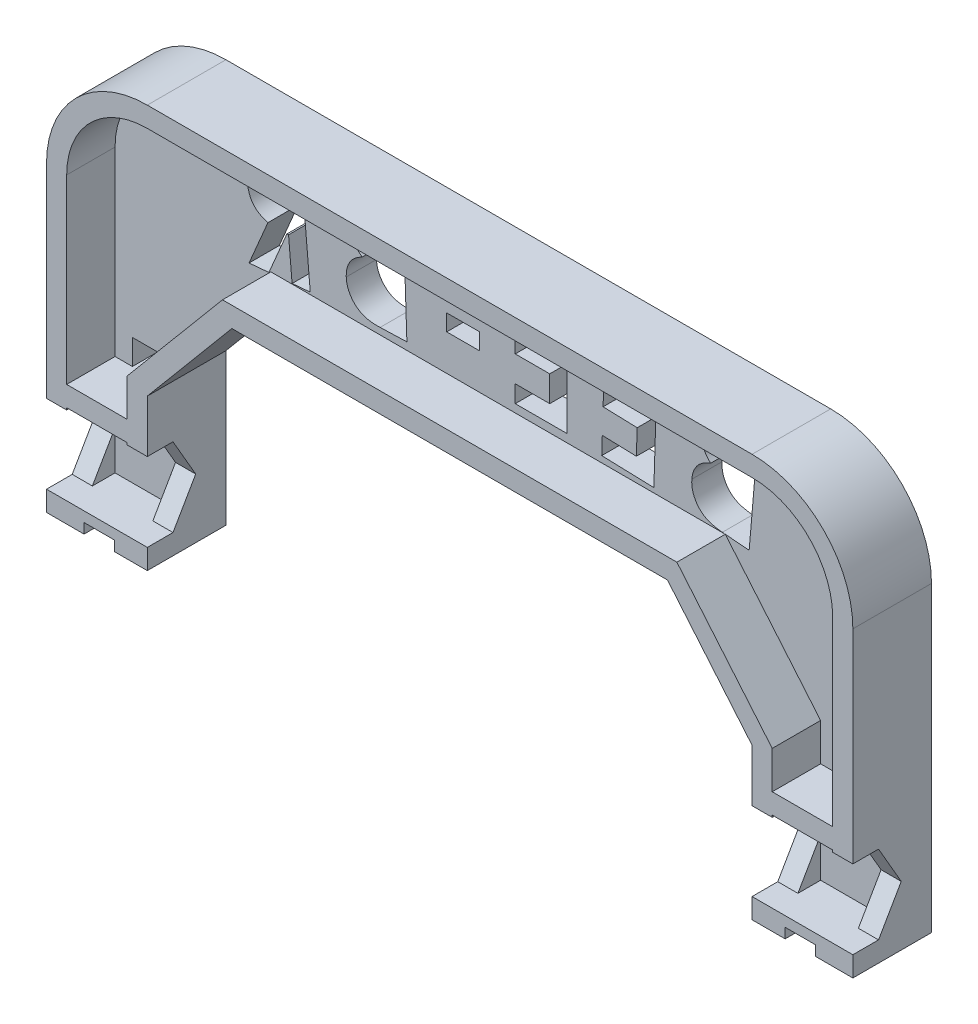
from build123d import *

# Parameters (mm, degrees)
RESSALTO_EXTRUS_O1_DEPTH      = 3
ESBO_O1_4_W                   = 2
ESBO_O1_4_H                   = 2
ESBO_O1_4_W_2                 = 6
ESBO_O1_4_H_2                 = 8
RESSALTO_EXTRUS_O2_DEPTH      = 7.8
RESSALTO_EXTRUS_O3_START      = 7.8
ESBO_O1_5_W                   = 2
ESBO_O1_5_H                   = 8
ESBO_O1_5_H_2                 = 2
ESBO_O1_5_W_2                 = 6
RESSALTO_EXTRUS_O3_DEPTH      = 6.5
RESSALTO_EXTRUS_O3_DEPTH_BACK = 1
CORTE_EXTRUS_O1_DEPTH         = 86.026407663
CORTE_EXTRUS_O2_DEPTH         = 90.8
CORTE_EXTRUS_O3_START         = -12
ESBO_O6_W                     = 80
ESBO_O6_H                     = 6.5
CORTE_EXTRUS_O3_DEPTH         = 12
ESBO_O8_W                     = 3
ESBO_O8_H                     = 2.5
ESBO_O8_H_2                   = 1
CORTE_EXTRUS_O4_DEPTH         = 19


with BuildPart() as part:
    # Esboço1 → Ressalto-extrusão1 (new body)
    with BuildSketch(Plane.XY):
        with BuildLine():
            Line((-30, -10), (-21.609003688, 0))
            Line((-21.609003688, 0), (21.609003688, 0))
            Line((21.609003688, 0), (30, -10))
            Line((30, -10), (30, -25))
            Line((30, -25), (40, -25))
            Line((40, -25), (40, 5))
            ThreePointArc((40, 5), (37.071067812, 12.071067812), (30, 15))
            Line((30, 15), (-30, 15))
            ThreePointArc((-30, 15), (-37.071067812, 12.071067812), (-40, 5))
            Line((-40, 5), (-40, -25))
            Line((-40, -25), (-30, -25))
            Line((-30, -25), (-30, -10))
        make_face()
    extrude(amount=RESSALTO_EXTRUS_O1_DEPTH)

    # Esboço1<4> → Ressalto-extrusão2 (add)
    with BuildSketch(Plane.XY):
        Polygon((-32, -25), (-32, -23), (-38, -23), (-40, -23), (-40, -25), align=None)
        with Locations((-31, -24)):
            Rectangle(ESBO_O1_4_W, ESBO_O1_4_H)
        with Locations((-35, -14)):
            Rectangle(ESBO_O1_4_W_2, ESBO_O1_4_H)
        with Locations((-31, -14)):
            Rectangle(ESBO_O1_4_W, ESBO_O1_4_H)
        with Locations((-39, -14)):
            Rectangle(ESBO_O1_4_W, ESBO_O1_4_H)
        Polygon((-32, -13), (-30, -13), (-30, -10), (-21.609003688, 0), (21.609003688, 0), (30, -10), (30, -13), (32, -13), (32, -9.272059531), (22.541619005, 2), (-22.541619005, 2), (-32, -9.272059531), align=None)
        with BuildLine():
            Line((-40, -13), (-38, -13))
            Line((-38, -13), (-38, 5))
            ThreePointArc((-38, 5), (-35.656854249, 10.656854249), (-30, 13))
            Line((-30, 13), (30, 13))
            ThreePointArc((30, 13), (35.656854249, 10.656854249), (38, 5))
            Line((38, 5), (38, -13))
            Line((38, -13), (40, -13))
            Line((40, -13), (40, 5))
            ThreePointArc((40, 5), (37.071067812, 12.071067812), (30, 15))
            Line((30, 15), (-30, 15))
            ThreePointArc((-30, 15), (-37.071067812, 12.071067812), (-40, 5))
            Line((-40, 5), (-40, -13))
        make_face()
        with Locations((39, -14)):
            Rectangle(ESBO_O1_4_W, ESBO_O1_4_H)
        with Locations((31, -14)):
            Rectangle(ESBO_O1_4_W, ESBO_O1_4_H)
        with Locations((31, -24)):
            Rectangle(ESBO_O1_4_W, ESBO_O1_4_H)
        Polygon((38, -23), (32, -23), (32, -25), (40, -25), (40, -23), align=None)
        with Locations((35, -14)):
            Rectangle(ESBO_O1_4_W_2, ESBO_O1_4_H)
        with Locations((-31, -19)):
            Rectangle(ESBO_O1_4_W, ESBO_O1_4_H_2)
        with Locations((-39, -19)):
            Rectangle(ESBO_O1_4_W, ESBO_O1_4_H_2)
        with Locations((39, -19)):
            Rectangle(ESBO_O1_4_W, ESBO_O1_4_H_2)
        with Locations((31, -19)):
            Rectangle(ESBO_O1_4_W, ESBO_O1_4_H_2)
    extrude(amount=RESSALTO_EXTRUS_O2_DEPTH)

    # Esboço1<5> → Ressalto-extrusão3 (add, two sides)
    with BuildSketch(Plane.XY.offset(RESSALTO_EXTRUS_O3_START)) as ressalto_extrus_o3_sk:
        with Locations((-39, -19)):
            Rectangle(ESBO_O1_5_W, ESBO_O1_5_H)
        Polygon((-32, -25), (-32, -23), (-38, -23), (-40, -23), (-40, -25), align=None)
        with Locations((-31, -24)):
            Rectangle(ESBO_O1_5_W, ESBO_O1_5_H_2)
        with Locations((-31, -14)):
            Rectangle(ESBO_O1_5_W, ESBO_O1_5_H_2)
        with Locations((-35, -14)):
            Rectangle(ESBO_O1_5_W_2, ESBO_O1_5_H_2)
        with Locations((-39, -14)):
            Rectangle(ESBO_O1_5_W, ESBO_O1_5_H_2)
        with Locations((-31, -19)):
            Rectangle(ESBO_O1_5_W, ESBO_O1_5_H)
        Polygon((38, -23), (32, -23), (32, -25), (40, -25), (40, -23), align=None)
        with Locations((31, -24)):
            Rectangle(ESBO_O1_5_W, ESBO_O1_5_H_2)
        with Locations((31, -19)):
            Rectangle(ESBO_O1_5_W, ESBO_O1_5_H)
        with Locations((31, -14)):
            Rectangle(ESBO_O1_5_W, ESBO_O1_5_H_2)
        with Locations((39, -19)):
            Rectangle(ESBO_O1_5_W, ESBO_O1_5_H)
        with Locations((39, -14)):
            Rectangle(ESBO_O1_5_W, ESBO_O1_5_H_2)
        with Locations((35, -14)):
            Rectangle(ESBO_O1_5_W_2, ESBO_O1_5_H_2)
    extrude(amount=RESSALTO_EXTRUS_O3_DEPTH)
    extrude(ressalto_extrus_o3_sk.sketch, amount=-RESSALTO_EXTRUS_O3_DEPTH_BACK)

    # Esboço2 → Corte-extrusão1 (cut, through all)
    with BuildSketch(Plane.ZY.offset(40)):
        Polygon((5.25166605, -23), (9.75499815, -23), (12.006664199, -19.1), (9.75499815, -15.2), (5.25166605, -15.2), (3, -19.1), align=None)
    extrude(amount=-CORTE_EXTRUS_O1_DEPTH, mode=Mode.SUBTRACT)

    # Esboço3 → Corte-extrusão2 (cut)
    with BuildSketch(Plane(origin=(0, 0, 0), x_dir=(-1, 0, 0), z_dir=(0, 0, -1))):
        with BuildLine():
            Line((-24.910939522, 1.799479276), (-25.721861998, 11.272961848))
            Line((-25.721861998, 11.272961848), (-24.233580748, 11.398893338))
            add(Edge.make_bspline(
                [(-24.233580748, 11.398893338), (-24.129306745, 11.407586683), (-23.927889288, 11.424378897), (-23.636514212, 11.441755378), (-23.366119032, 11.450688984), (-23.117357078, 11.456285064), (-22.889523075, 11.449775412), (-22.683425617, 11.438280168), (-22.49763069, 11.423568073), (-22.382019918, 11.402918558), (-22.327435916, 11.39316918)],
                knots=[0, 0, 0, 0, 1.313966022, 2.538079354, 3.664944948, 4.71135529, 5.662102467, 6.526021516, 7.304081761, 8, 8, 8, 8], degree=3))
            add(Edge.make_bspline(
                [(-22.327435916, 11.39316918), (-22.256593664, 11.379606887), (-22.116905433, 11.352864474), (-21.914216589, 11.294833367), (-21.720702926, 11.224614715), (-21.537670734, 11.139742514), (-21.362339691, 11.045688204), (-21.200529267, 10.932607536), (-21.044931075, 10.811853962), (-20.902174658, 10.675500117), (-20.771008955, 10.52969755), (-20.654089611, 10.374606719), (-20.552536162, 10.21180895), (-20.465900549, 10.040855527), (-20.395091314, 9.860665842), (-20.34055482, 9.672111647), (-20.299139833, 9.475705497), (-20.285251037, 9.341553089), (-20.278187118, 9.273322425)],
                knots=[0, 0, 0, 0, 1.085588587, 2.140586228, 3.170688593, 4.182012061, 5.176371104, 6.161836047, 7.150460134, 8.139501588, 9.129655157, 10.100729556, 11.060021403, 12.015097404, 12.982528871, 13.970456957, 14.967763074, 16, 16, 16, 16], degree=3))
            add(Edge.make_bspline(
                [(-20.278187118, 9.273322425), (-20.272812811, 9.184926321), (-20.262243451, 9.011082451), (-20.284254904, 8.753922925), (-20.335995005, 8.506479089), (-20.419238502, 8.268263892), (-20.532889076, 8.034838038), (-20.686063901, 7.810369103), (-20.872901117, 7.587889131), (-21.018854751, 7.451522345), (-21.094833753, 7.380533963)],
                knots=[0, 0, 0, 0, 0.988972813, 1.944959711, 2.87510724, 3.808293588, 4.759083714, 5.768773294, 6.838491573, 8, 8, 8, 8], degree=3))
            add(Edge.make_bspline(
                [(-21.094833753, 7.380533963), (-21.021908785, 7.352906395), (-20.878709221, 7.298655348), (-20.675800835, 7.20224047), (-20.48471665, 7.101842949), (-20.309982528, 6.99028723), (-20.146823666, 6.874766863), (-19.998504415, 6.749899451), (-19.865661335, 6.616087659), (-19.744226803, 6.47649637), (-19.636605473, 6.328222872), (-19.541507261, 6.171583391), (-19.457455709, 6.007906157), (-19.3858424, 5.835684545), (-19.327736255, 5.655453876), (-19.279928619, 5.46749254), (-19.242455728, 5.271999148), (-19.22958728, 5.138081193), (-19.223033873, 5.06988192)],
                knots=[0, 0, 0, 0, 1.181829229, 2.320706277, 3.403542679, 4.452266086, 5.461131016, 6.432812402, 7.387405613, 8.317228163, 9.235326515, 10.161441584, 11.092962624, 12.022385079, 12.985994604, 13.96125793, 14.961746936, 16, 16, 16, 16], degree=3))
            add(Edge.make_bspline(
                [(-19.223033873, 5.06988192), (-19.2165564, 4.938770926), (-19.203777409, 4.680110426), (-19.253126284, 4.296623788), (-19.349384328, 3.925687081), (-19.50368905, 3.575612965), (-19.696036732, 3.250762823), (-19.925938036, 2.960709753), (-20.188646227, 2.708114681), (-20.437995214, 2.53202002), (-20.655623267, 2.410108848), (-20.836195565, 2.327732639), (-21.033230053, 2.256447188), (-21.246166827, 2.190501189), (-21.475860065, 2.136425446), (-21.721760262, 2.090990357), (-21.98322567, 2.052047931), (-22.163878063, 2.035204726), (-22.256837959, 2.026537569)],
                knots=[0, 0, 0, 0, 1.29558415, 2.555975173, 3.805148212, 5.072546849, 6.324565388, 7.528543806, 8.720458455, 9.915603118, 10.534905023, 11.184890737, 11.875232468, 12.605216168, 13.387618399, 14.206515762, 15.07711098, 16, 16, 16, 16], degree=3))
            Line((-22.256837959, 2.026537569), (-24.910939522, 1.799479276))
        make_face()
        with BuildLine():
            Line((-23.77183195, 9.708358483), (-23.602015243, 7.710627112))
            Line((-23.602015243, 7.710627112), (-23.208956349, 7.743064012))
            add(Edge.make_bspline(
                [(-23.208956349, 7.743064012), (-23.106739431, 7.754930871), (-22.9144479, 7.77725493), (-22.649227364, 7.850315967), (-22.429180251, 7.957141317), (-22.252536531, 8.094651338), (-22.125831592, 8.262990624), (-22.036038848, 8.4505902), (-21.993909403, 8.662272792), (-21.999937434, 8.80827937), (-22.003066926, 8.884079637)],
                knots=[0, 0, 0, 0, 1.309259117, 2.462991907, 3.484474685, 4.40662182, 5.284673551, 6.143423425, 7.036146178, 8, 8, 8, 8], degree=3))
            add(Edge.make_bspline(
                [(-22.003066926, 8.884079637), (-22.01212709, 8.954724988), (-22.029567142, 9.090711336), (-22.104352351, 9.278770734), (-22.215618085, 9.439828669), (-22.364979607, 9.571664428), (-22.548814746, 9.674928381), (-22.772119257, 9.735640607), (-23.029045347, 9.764354457), (-23.211476833, 9.752698049), (-23.308175099, 9.74651954)],
                knots=[0, 0, 0, 0, 0.960098706, 1.848109079, 2.707028349, 3.584142476, 4.519774804, 5.532262408, 6.691969519, 8, 8, 8, 8], degree=3))
            Line((-23.308175099, 9.74651954), (-23.77183195, 9.708358483))
        make_face(mode=Mode.SUBTRACT)
        with BuildLine():
            Line((-23.462727383, 6.102138531), (-23.254749618, 3.673187209))
            Line((-23.254749618, 3.673187209), (-22.804449137, 3.711348266))
            add(Edge.make_bspline(
                [(-22.804449137, 3.711348266), (-22.714691252, 3.719501259), (-22.543051933, 3.735091803), (-22.297871283, 3.769308394), (-22.076494908, 3.811552918), (-21.877722721, 3.857566086), (-21.703338355, 3.913500415), (-21.551602907, 3.972992402), (-21.42369243, 4.041714531), (-21.318877192, 4.118903482), (-21.233058423, 4.203638893), (-21.159747546, 4.293260641), (-21.099923793, 4.391482552), (-21.054759937, 4.497247706), (-21.019633271, 4.608287537), (-20.998745443, 4.726863702), (-20.990978732, 4.8523745), (-20.996573039, 4.938242481), (-20.999431108, 4.982111487)],
                knots=[0, 0, 0, 0, 1.719239493, 3.287611936, 4.720190196, 6.018023643, 7.176886393, 8.211086977, 9.123282731, 9.938670018, 10.685153, 11.41850386, 12.142662851, 12.870775423, 13.607631086, 14.359713874, 15.16199587, 16, 16, 16, 16], degree=3))
            add(Edge.make_bspline(
                [(-20.999431108, 4.982111487), (-21.004442252, 5.031957285), (-21.014182719, 5.128845623), (-21.051022788, 5.267498336), (-21.095140571, 5.398489283), (-21.157148766, 5.519294292), (-21.2327144, 5.630761305), (-21.319782864, 5.735265672), (-21.425075794, 5.825603224), (-21.539375723, 5.911602032), (-21.671611588, 5.98433719), (-21.820892623, 6.046366943), (-21.989770057, 6.089007611), (-22.174570729, 6.127883069), (-22.377975566, 6.145932384), (-22.598888308, 6.156197182), (-22.837844443, 6.151981213), (-23.002940146, 6.139272671), (-23.088749017, 6.132667377)],
                knots=[0, 0, 0, 0, 0.887704196, 1.72548518, 2.539505422, 3.337158996, 4.126138673, 4.926901397, 5.74248556, 6.58239328, 7.461732246, 8.413447965, 9.443111175, 10.547821151, 11.762049063, 13.061444902, 14.472679217, 16, 16, 16, 16], degree=3))
            Line((-23.088749017, 6.132667377), (-23.462727383, 6.102138531))
        make_face(mode=Mode.SUBTRACT)
        Polygon((-15.756681011, 11.935736384), (-10.58394964, 12.099828932), (-10.528616107, 10.334880014), (-13.909685818, 10.228029053), (-13.854352285, 8.514597562), (-10.473282573, 8.621448524), (-10.419857092, 6.888936505), (-13.800926804, 6.782085543), (-13.720788583, 4.290168476), (-10.339718871, 4.397019437), (-10.284385337, 2.62634636), (-15.457116708, 2.462253812), align=None)
        Polygon((-6.832522431, 12.324855334), (-1.703676277, 12.324855334), (-1.703676277, 10.61523995), (-5.122907046, 10.61523995), (-5.122907046, 8.78350918), (-1.703676277, 8.78350918), (-1.703676277, 7.073893796), (-5.122907046, 7.073893796), (-5.122907046, 4.509470719), (-1.703676277, 4.509470719), (-1.703676277, 2.799855334), (-6.832522431, 2.799855334), align=None)
        Polygon((1.829885506, 7.206468083), (5.102196203, 7.200743924), (5.098380097, 5.565542602), (1.8260694, 5.571266761), align=None)
        with BuildLine():
            Line((9.047182886, 2.736627532), (9.362011612, 12.210110104))
            Line((9.362011612, 12.210110104), (10.850292862, 12.160500729))
            add(Edge.make_bspline(
                [(10.850292862, 12.160500729), (10.954617699, 12.156424264), (11.155715083, 12.148566438), (11.446407616, 12.131137245), (11.714989946, 12.110979273), (11.961978819, 12.084770423), (12.186897757, 12.051297256), (12.390988765, 12.01846698), (12.572917568, 11.979523243), (12.684754634, 11.945587838), (12.737357164, 11.92962633)],
                knots=[0, 0, 0, 0, 1.314487014, 2.533815602, 3.666356561, 4.70543794, 5.660122908, 6.529004863, 7.308117873, 8, 8, 8, 8], degree=3))
            add(Edge.make_bspline(
                [(12.737357164, 11.92962633), (12.805812519, 11.907831137), (12.941388921, 11.864665575), (13.134532865, 11.781820277), (13.318286416, 11.690193294), (13.489678395, 11.585069637), (13.650589339, 11.468493899), (13.799954, 11.34023818), (13.937756757, 11.200445091), (14.063679706, 11.049961375), (14.175518286, 10.89011754), (14.274308469, 10.723787821), (14.353898504, 10.549298292), (14.419007429, 10.369369583), (14.469633958, 10.183217996), (14.500935549, 9.990095509), (14.519017758, 9.791054996), (14.518056887, 9.656536843), (14.517570506, 9.58844544)],
                knots=[0, 0, 0, 0, 1.084518904, 2.147898747, 3.17039799, 4.183649399, 5.180927192, 6.168721053, 7.153708144, 8.142622483, 9.128733241, 10.09751886, 11.060332373, 12.020602502, 12.985331112, 13.969240152, 14.97205483, 16, 16, 16, 16], degree=3))
            add(Edge.make_bspline(
                [(14.517570506, 9.58844544), (14.512115291, 9.500412161), (14.501392606, 9.327375306), (14.448023476, 9.075055604), (14.368624561, 8.835610516), (14.258104474, 8.609225337), (14.116342253, 8.394531695), (13.94049855, 8.188609431), (13.727465561, 7.992133517), (13.566667849, 7.873485071), (13.483405842, 7.812048205)],
                knots=[0, 0, 0, 0, 0.987986378, 1.941970776, 2.882502406, 3.810757125, 4.758320916, 5.760163861, 6.840199605, 8, 8, 8, 8], degree=3))
            add(Edge.make_bspline(
                [(13.483405842, 7.812048205), (13.552432386, 7.775137032), (13.687160291, 7.703092791), (13.879418749, 7.586956559), (14.054215993, 7.462426607), (14.216453734, 7.334312459), (14.363121119, 7.199059692), (14.495376888, 7.057643259), (14.612407375, 6.910390454), (14.713904845, 6.756803323), (14.802127587, 6.597116902), (14.87879031, 6.431558288), (14.941036269, 6.258843269), (14.994322887, 6.080993584), (15.028787885, 5.895331821), (15.054572103, 5.70371369), (15.065548248, 5.50533669), (15.064038573, 5.371017402), (15.063273631, 5.302958661)],
                knots=[0, 0, 0, 0, 1.19002917, 2.322731646, 3.412004466, 4.451014966, 5.463821004, 6.442204954, 7.392124064, 8.320083953, 9.237708086, 10.16365045, 11.090602125, 12.027038084, 12.982845179, 13.957974222, 14.965318353, 16, 16, 16, 16], degree=3))
            add(Edge.make_bspline(
                [(15.063273631, 5.302958661), (15.054388785, 5.1726828), (15.03685168, 4.915541443), (14.943914679, 4.5415548), (14.802007182, 4.186663194), (14.609139979, 3.857557516), (14.379614189, 3.558671073), (14.118218178, 3.298106879), (13.827264046, 3.080336393), (13.561341181, 2.934490559), (13.331796006, 2.839103853), (13.142803872, 2.781767484), (12.939885406, 2.731183261), (12.721000131, 2.694090774), (12.48738438, 2.665328812), (12.238346166, 2.648545964), (11.974771493, 2.643185307), (11.794138596, 2.646931416), (11.701284448, 2.648857099)],
                knots=[0, 0, 0, 0, 1.293209402, 2.552565116, 3.803787532, 5.073091564, 6.323645754, 7.532624737, 8.722505474, 9.916843678, 10.530766191, 11.185263696, 11.873842807, 12.604054984, 13.385812867, 14.207947857, 15.078797514, 16, 16, 16, 16], degree=3))
            Line((11.701284448, 2.648857099), (9.047182886, 2.736627532))
        make_face()
        with BuildLine():
            Line((11.107880001, 10.431804815), (11.04109815, 8.434073445))
            Line((11.04109815, 8.434073445), (11.434157044, 8.420717075))
            add(Edge.make_bspline(
                [(11.434157044, 8.420717075), (11.536663867, 8.420603604), (11.729373073, 8.420390282), (12.000185411, 8.45992278), (12.230513128, 8.540105199), (12.421230156, 8.655658098), (12.568967197, 8.805722715), (12.676580129, 8.982745991), (12.745754379, 9.186118413), (12.756549488, 9.331563622), (12.762161852, 9.407180416)],
                knots=[0, 0, 0, 0, 1.308947509, 2.46077507, 3.478771254, 4.405781035, 5.285103298, 6.142362923, 7.034216663, 8, 8, 8, 8], degree=3))
            add(Edge.make_bspline(
                [(12.762161852, 9.407180416), (12.761337853, 9.478072106), (12.759755121, 9.614240359), (12.70884135, 9.809261656), (12.616472726, 9.98099358), (12.486189332, 10.131437373), (12.313958919, 10.252549896), (12.10182118, 10.343074823), (11.849526161, 10.398134283), (11.667853327, 10.410163127), (11.571536852, 10.416540392)],
                knots=[0, 0, 0, 0, 0.958911669, 1.841870698, 2.70246622, 3.582935599, 4.516525514, 5.53255725, 6.691849617, 8, 8, 8, 8], degree=3))
            Line((11.571536852, 10.416540392), (11.107880001, 10.431804815))
        make_face(mode=Mode.SUBTRACT)
        with BuildLine():
            Line((10.987672669, 6.825584863), (10.907534448, 4.396633541))
            Line((10.907534448, 4.396633541), (11.357834929, 4.381369118))
            add(Edge.make_bspline(
                [(11.357834929, 4.381369118), (11.44750682, 4.379628128), (11.619220558, 4.376294285), (11.86624788, 4.378918583), (12.090484961, 4.393778634), (12.29220197, 4.419158544), (12.472079165, 4.44945066), (12.629202013, 4.493408312), (12.764252295, 4.545880154), (12.877821928, 4.609880599), (12.972534572, 4.684323071), (13.055103822, 4.764853914), (13.127912782, 4.853158567), (13.183459828, 4.953040008), (13.230791359, 5.059382038), (13.264204141, 5.174302816), (13.288398443, 5.29754412), (13.29243119, 5.382974014), (13.294508607, 5.426982099)],
                knots=[0, 0, 0, 0, 1.715703643, 3.285420693, 4.724409075, 6.011686423, 7.173926675, 8.210114093, 9.127403779, 9.939309915, 10.693755025, 11.425085138, 12.143343792, 12.873762464, 13.60387707, 14.366033249, 15.158283534, 16, 16, 16, 16], degree=3))
            add(Edge.make_bspline(
                [(13.294508607, 5.426982099), (13.295047998, 5.4766461), (13.296102847, 5.573770524), (13.277820396, 5.715689158), (13.24766946, 5.850898215), (13.202358213, 5.978868453), (13.140120905, 6.098062481), (13.064710385, 6.210106062), (12.975388387, 6.315518636), (12.868547071, 6.410811985), (12.74774755, 6.501112921), (12.605028352, 6.575341425), (12.445478301, 6.643661485), (12.265203814, 6.697172712), (12.066561646, 6.74353968), (11.848275529, 6.776387493), (11.611502066, 6.802104535), (11.446948361, 6.808772248), (11.361651035, 6.812228493)],
                knots=[0, 0, 0, 0, 0.883019077, 1.726858855, 2.539682352, 3.345301018, 4.135097291, 4.926271423, 5.745220041, 6.586626684, 7.469645761, 8.421857886, 9.441522381, 10.555073518, 11.763276166, 13.069723502, 14.481074902, 16, 16, 16, 16], degree=3))
            Line((11.361651035, 6.812228493), (10.987672669, 6.825584863))
        make_face(mode=Mode.SUBTRACT)
        with BuildLine():
            Line((19.461989353, 11.685693059), (21.375766397, 11.517784406))
            add(Edge.make_bspline(
                [(21.375766397, 11.517784406), (21.501767184, 11.505709202), (21.744545188, 11.48244273), (22.093843999, 11.438490066), (22.414023077, 11.38953689), (22.705715408, 11.334495926), (22.968536679, 11.272990007), (23.201163323, 11.201831836), (23.406184383, 11.128599072), (23.584391582, 11.045063928), (23.744484859, 10.953635256), (23.891294989, 10.852006444), (24.030425405, 10.740587669), (24.159405903, 10.617356744), (24.277761125, 10.482105066), (24.390165475, 10.338884293), (24.48999886, 10.182158981), (24.58180952, 10.016761072), (24.661714289, 9.842502304), (24.73115437, 9.662005721), (24.783947812, 9.474005489), (24.824631824, 9.280246022), (24.850187924, 9.079866499), (24.866597889, 8.873545), (24.86612308, 8.660525163), (24.85565978, 8.517006792), (24.850330699, 8.443911208)],
                knots=[0, 0, 0, 0, 1.706242283, 3.287583397, 4.745122099, 6.071840018, 7.288377294, 8.381422042, 9.349801241, 10.220491494, 11.030836279, 11.832287683, 12.624977777, 13.43150359, 14.233230108, 15.046110905, 15.883227537, 16.735141512, 17.59444415, 18.465472044, 19.339322555, 20.223791933, 21.132003346, 22.060506007, 23.012193042, 24, 24, 24, 24], degree=3))
            add(Edge.make_bspline(
                [(24.850330699, 8.443911208), (24.842481921, 8.367448333), (24.827102426, 8.217621144), (24.786587291, 7.999566654), (24.733052329, 7.792356221), (24.666798522, 7.595584178), (24.586026586, 7.410401259), (24.494587235, 7.234564511), (24.387228995, 7.071357911), (24.268845979, 6.917412374), (24.135871219, 6.775053948), (23.989112069, 6.644238027), (23.830011984, 6.52301575), (23.65666455, 6.413883545), (23.470298081, 6.315354116), (23.270354423, 6.226682441), (23.05685027, 6.151151627), (22.908809384, 6.108935937), (22.8335188, 6.087465896)],
                knots=[0, 0, 0, 0, 1.103647808, 2.162571673, 3.181780949, 4.175536025, 5.141138738, 6.08098974, 7.018484832, 7.943073067, 8.867345349, 9.811846367, 10.763740163, 11.736918372, 12.750380027, 13.789214674, 14.87563955, 16, 16, 16, 16], degree=3))
            Line((22.8335188, 6.087465896), (24.707226733, 1.679863732))
            Line((24.707226733, 1.679863732), (22.736208103, 1.853496545))
            Line((22.736208103, 1.853496545), (20.955994762, 6.051212891))
            Line((20.955994762, 6.051212891), (20.788086108, 6.066477314))
            Line((20.788086108, 6.066477314), (20.437004377, 2.053842098))
            Line((20.437004377, 2.053842098), (18.633894401, 2.212210487))
            Line((18.633894401, 2.212210487), (19.461989353, 11.685693059))
        make_face()
        with BuildLine():
            Line((20.940730339, 7.823794021), (21.507422046, 7.774184646))
            add(Edge.make_bspline(
                [(21.507422046, 7.774184646), (21.576707583, 7.768479905), (21.709415838, 7.757553148), (21.901100393, 7.751592664), (22.076205889, 7.755456212), (22.235486918, 7.766414791), (22.378929021, 7.78529265), (22.507008086, 7.810843988), (22.618966193, 7.846413258), (22.743386051, 7.90766501), (22.878033175, 8.00820513), (22.996590727, 8.175888507), (23.07556977, 8.382652493), (23.095680455, 8.534774801), (23.106370363, 8.615635968)],
                knots=[0, 0, 0, 0, 1.202426501, 2.303105821, 3.315514564, 4.231050406, 5.063490919, 5.816534758, 6.48800783, 7.08828922, 8.210531185, 9.352658199, 10.592795835, 12, 12, 12, 12], degree=3))
            add(Edge.make_bspline(
                [(23.106370363, 8.615635968), (23.109451398, 8.665938222), (23.115443764, 8.763772095), (23.094021973, 8.90699539), (23.057140354, 9.043062021), (22.994725788, 9.16828291), (22.917588593, 9.282494137), (22.823576951, 9.382416284), (22.71400471, 9.466547214), (22.582201116, 9.539343125), (22.413992003, 9.599634329), (22.195033636, 9.645699323), (21.92072743, 9.690019557), (21.717483398, 9.708442997), (21.606640796, 9.718490535)],
                knots=[0, 0, 0, 0, 0.850414144, 1.653987699, 2.43742129, 3.226745441, 4.008773503, 4.762447895, 5.537335357, 6.336935986, 7.300476977, 8.548276045, 10.117543424, 12, 12, 12, 12], degree=3))
            Line((21.606640796, 9.718490535), (21.110547046, 9.762375752))
            Line((21.110547046, 9.762375752), (20.940730339, 7.823794021))
        make_face(mode=Mode.SUBTRACT)
    extrude(amount=-CORTE_EXTRUS_O2_DEPTH, mode=Mode.SUBTRACT)


with BuildPart() as corte_extrus_o2_piece_1:
    # of the separate pieces the step leaves, piece 1, a body of its own (corte_extrus_o2_pieces)
    add(part.part.solids().sort_by_distance((-30, 15, 7.8))[0])

    # Esboço6 → Corte-extrusão3 (cut)
    with BuildSketch(Plane.XZ.offset(25).offset(CORTE_EXTRUS_O3_START)):
        with Locations((0, 11.05)):
            Rectangle(ESBO_O6_W, ESBO_O6_H)
    extrude(amount=CORTE_EXTRUS_O3_DEPTH, mode=Mode.SUBTRACT)

    # Esboço8 → Corte-extrusão4 (cut)
    with BuildSketch(Plane.XY.offset(7.8)):
        with Locations((-34.778900571, -11.75)):
            Rectangle(ESBO_O8_W, ESBO_O8_H)
        with Locations((-34.778900571, -24.5)):
            Rectangle(ESBO_O8_W, ESBO_O8_H_2)
    corte_extrus_o4 = extrude(amount=-CORTE_EXTRUS_O4_DEPTH, mode=Mode.SUBTRACT)

    # Espelhar1: Corte-extrusão4 across plane
    add(corte_extrus_o4.mirror(Plane(origin=(0, 0, 0), x_dir=(0, 0, 1), z_dir=(1, 0, 0))), mode=Mode.SUBTRACT)


with BuildPart() as corte_extrus_o2_piece_2:
    # of the separate pieces the step leaves, piece 2, a body of its own (corte_extrus_o2_pieces)
    add(part.part.solids().sort_by_distance((23.462727383, 6.102138531, 0))[0])


with BuildPart() as corte_extrus_o2_piece_3:
    # of the separate pieces the step leaves, piece 3, a body of its own (corte_extrus_o2_pieces)
    add(part.part.solids().sort_by_distance((-10.987672669, 6.825584863, 0))[0])


with BuildPart() as corte_extrus_o2_piece_4:
    # of the separate pieces the step leaves, piece 4, a body of its own (corte_extrus_o2_pieces)
    add(part.part.solids().sort_by_distance((-20.940730339, 7.823794021, 0))[0])


with BuildPart() as corte_extrus_o2_piece_5:
    # of the separate pieces the step leaves, piece 5, a body of its own (corte_extrus_o2_pieces)
    add(part.part.solids().sort_by_distance((23.77183195, 9.708358483, 0))[0])


with BuildPart() as corte_extrus_o2_piece_6:
    # of the separate pieces the step leaves, piece 6, a body of its own (corte_extrus_o2_pieces)
    add(part.part.solids().sort_by_distance((-11.107880001, 10.431804815, 0))[0])


solid = corte_extrus_o2_piece_1.part
